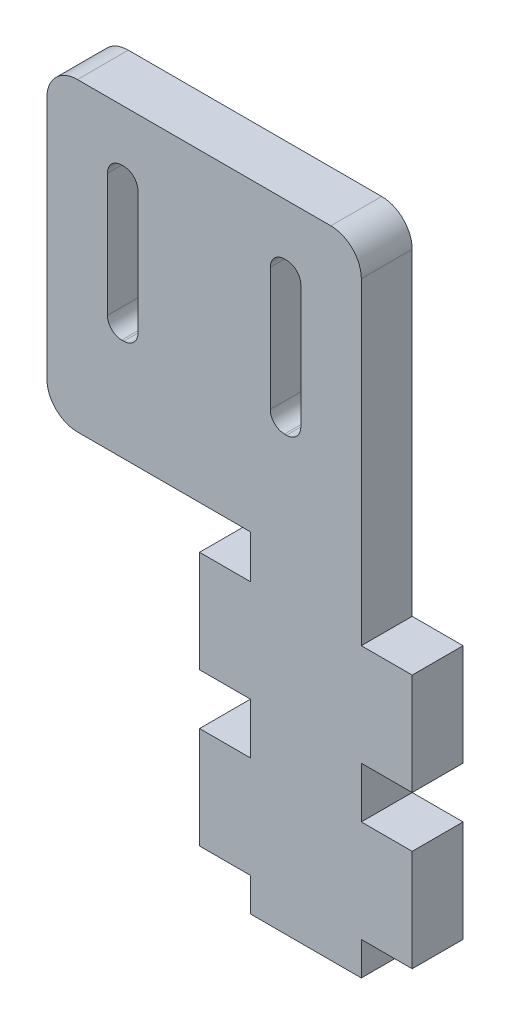
from build123d import *

# Parameters (mm, degrees)
BOSS_EXTRUDE1_DEPTH = 5


with BuildPart() as part:
    # Sketch1 → Boss-Extrude1 (new body)
    with BuildSketch(Plane.XY):
        with BuildLine():
            Line((-10.45, -25.774734933), (-10.45, -35.774734933))
            Line((-10.45, -35.774734933), (-5.45, -35.774734933))
            Line((-5.45, -35.774734933), (-5.45, -39.058458692))
            Line((-5.45, -39.058458692), (5.45, -39.058458692))
            Line((5.45, -39.058458692), (5.45, -35.774734933))
            Line((5.45, -35.774734933), (10.45, -35.774734933))
            Line((10.45, -35.774734933), (10.45, -25.774734933))
            Line((10.45, -25.774734933), (5.45, -25.774734933))
            Line((5.45, -25.774734933), (5.45, -20.774734933))
            Line((5.45, -20.774734933), (10.45, -20.774734933))
            Line((10.45, -20.774734933), (10.45, -10.774734933))
            Line((10.45, -10.774734933), (5.45, -10.774734933))
            Line((5.45, -10.774734933), (5.45, 20.465265067))
            ThreePointArc((5.45, 20.465265067), (4.571320344, 22.586585411), (2.45, 23.465265067))
            Line((2.45, 23.465265067), (-22.45, 23.465265067))
            ThreePointArc((-22.45, 23.465265067), (-24.571320344, 22.586585411), (-25.45, 20.465265067))
            Line((-25.45, 20.465265067), (-25.45, -3.534734933))
            ThreePointArc((-25.45, -3.534734933), (-24.571320344, -5.656055277), (-22.45, -6.534734933))
            Line((-22.45, -6.534734933), (-5.45, -6.534734933))
            Line((-5.45, -6.534734933), (-5.45, -10.774734933))
            Line((-5.45, -10.774734933), (-10.45, -10.774734933))
            Line((-10.45, -10.774734933), (-10.45, -20.774734933))
            Line((-10.45, -20.774734933), (-5.45, -20.774734933))
            Line((-5.45, -20.774734933), (-5.45, -25.774734933))
            Line((-5.45, -25.774734933), (-10.45, -25.774734933))
        make_face()
        with BuildLine():
            Line((-19.50201423, 16.965265067), (-19.50201423, 4.865265067))
            ThreePointArc((-19.50201423, 4.865265067), (-19.091963724, 3.875315573), (-18.10201423, 3.465265067))
            Line((-18.10201423, 3.465265067), (-17.90201423, 3.465265067))
            ThreePointArc((-17.90201423, 3.465265067), (-16.912064737, 3.875315573), (-16.50201423, 4.865265067))
            Line((-16.50201423, 4.865265067), (-16.50201423, 16.965265067))
            ThreePointArc((-16.50201423, 16.965265067), (-16.912064737, 17.955214561), (-17.90201423, 18.365265067))
            Line((-17.90201423, 18.365265067), (-18.10201423, 18.365265067))
            ThreePointArc((-18.10201423, 18.365265067), (-19.091963724, 17.955214561), (-19.50201423, 16.965265067))
        make_face(mode=Mode.SUBTRACT)
        with BuildLine():
            Line((-3.49798577, 16.965265067), (-3.49798577, 4.865265067))
            ThreePointArc((-3.49798577, 4.865265067), (-3.087935263, 3.875315573), (-2.09798577, 3.465265067))
            Line((-2.09798577, 3.465265067), (-1.89798577, 3.465265067))
            ThreePointArc((-1.89798577, 3.465265067), (-0.908036276, 3.875315573), (-0.49798577, 4.865265067))
            Line((-0.49798577, 4.865265067), (-0.49798577, 16.965265067))
            ThreePointArc((-0.49798577, 16.965265067), (-0.908036276, 17.955214561), (-1.89798577, 18.365265067))
            Line((-1.89798577, 18.365265067), (-2.09798577, 18.365265067))
            ThreePointArc((-2.09798577, 18.365265067), (-3.087935263, 17.955214561), (-3.49798577, 16.965265067))
        make_face(mode=Mode.SUBTRACT)
    extrude(amount=BOSS_EXTRUDE1_DEPTH)


solid = part.part
